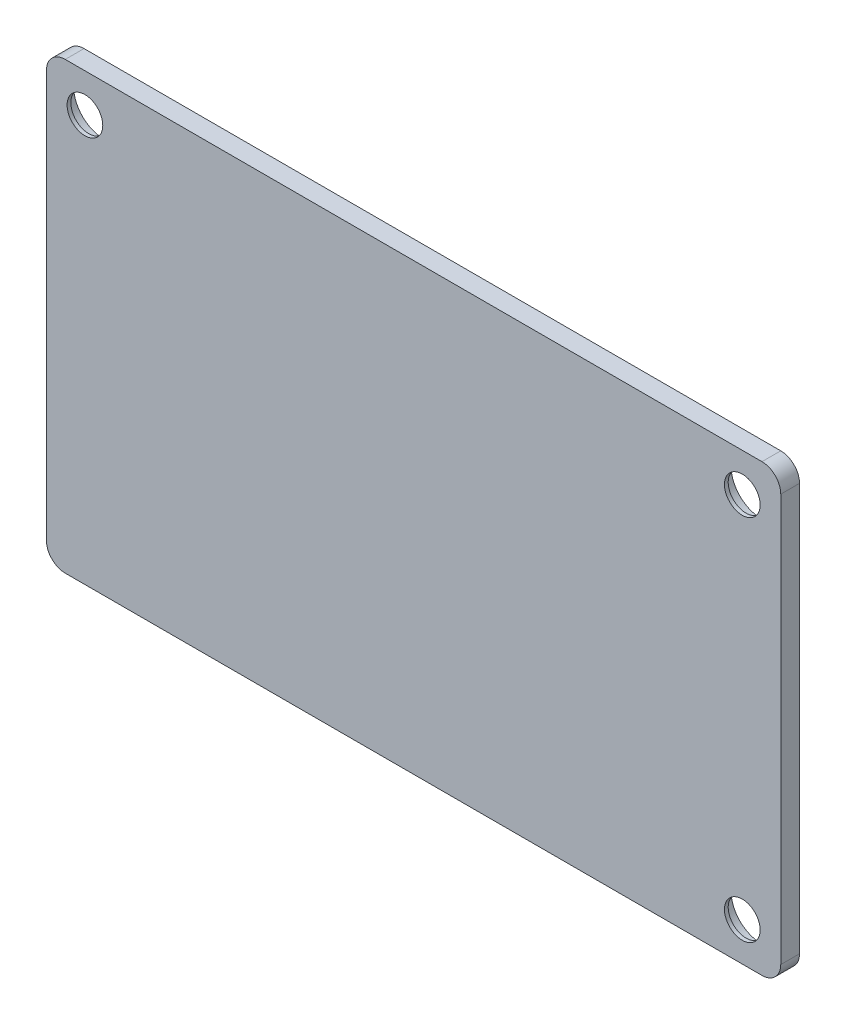
from build123d import *

# Parameters (mm, degrees)
SKETCH1_W           = 99.30160125
SKETCH1_H           = 60.173202502
SKETCH1_R           = 2.413
BOSS_EXTRUDE1_DEPTH = 2.54
SKETCH1_3_R         = 2.413
CUT_EXTRUDE1_DEPTH  = 2.54
SKETCH1_4_R         = 4.056034091
SKETCH1_4_R_2       = 2.413
CUT_EXTRUDE2_DEPTH  = 2.032
FILLET1_R           = 2.54


with BuildPart() as part:
    # Sketch1 → Boss-Extrude1 (new body)
    with BuildSketch(Plane.XY):
        with Locations((2.344221604, 0)):
            Rectangle(SKETCH1_W, SKETCH1_H)
        with Locations((46.794221604, -24.885800625)):
            Circle(SKETCH1_R, mode=Mode.SUBTRACT)
    extrude(amount=BOSS_EXTRUDE1_DEPTH)

    # Sketch1_3 → Cut-Extrude1 (cut)
    with BuildSketch(Plane.XY):
        with Locations((-42.105778396, 24.885800625)):
            Circle(SKETCH1_3_R)
        with Locations((46.794221604, 24.885800625)):
            Circle(SKETCH1_3_R)
        with Locations((46.794221604, -24.885800625)):
            Circle(SKETCH1_3_R)
    extrude(amount=CUT_EXTRUDE1_DEPTH, mode=Mode.SUBTRACT)

    # Sketch1_4 → Cut-Extrude2 (cut)
    # profile 1 of 3: a face of its own
    with BuildSketch(Plane.XY):
        with Locations((-42.105778396, 24.885800625)):
            Circle(SKETCH1_4_R)
        with Locations((-42.105778396, 24.885800625)):
            Circle(SKETCH1_4_R_2, mode=Mode.SUBTRACT)
    # profile 2 of 3: a face of its own
    with BuildSketch(Plane.XY):
        with Locations((46.794221604, 24.885800625)):
            Circle(SKETCH1_4_R)
        with Locations((46.794221604, 24.885800625)):
            Circle(SKETCH1_4_R_2, mode=Mode.SUBTRACT)
    # profile 3 of 3: a face of its own
    with BuildSketch(Plane.XY):
        with Locations((46.794221604, -24.885800625)):
            Circle(SKETCH1_4_R)
        with Locations((46.794221604, -24.885800625)):
            Circle(SKETCH1_4_R_2, mode=Mode.SUBTRACT)
    extrude(amount=CUT_EXTRUDE2_DEPTH, mode=Mode.SUBTRACT)

    # Fillet1
    fillet1_edges = [part.edges().sort_by_distance(p)[0] for p in [
        (-47.306579021, 30.086601251, 1.27),
        (-47.306579021, -30.086601251, 1.27),
        (51.995022229, -30.086601251, 1.27),
        (51.995022229, 30.086601251, 1.27),
    ]]
    fillet(fillet1_edges, radius=FILLET1_R)


solid = part.part
